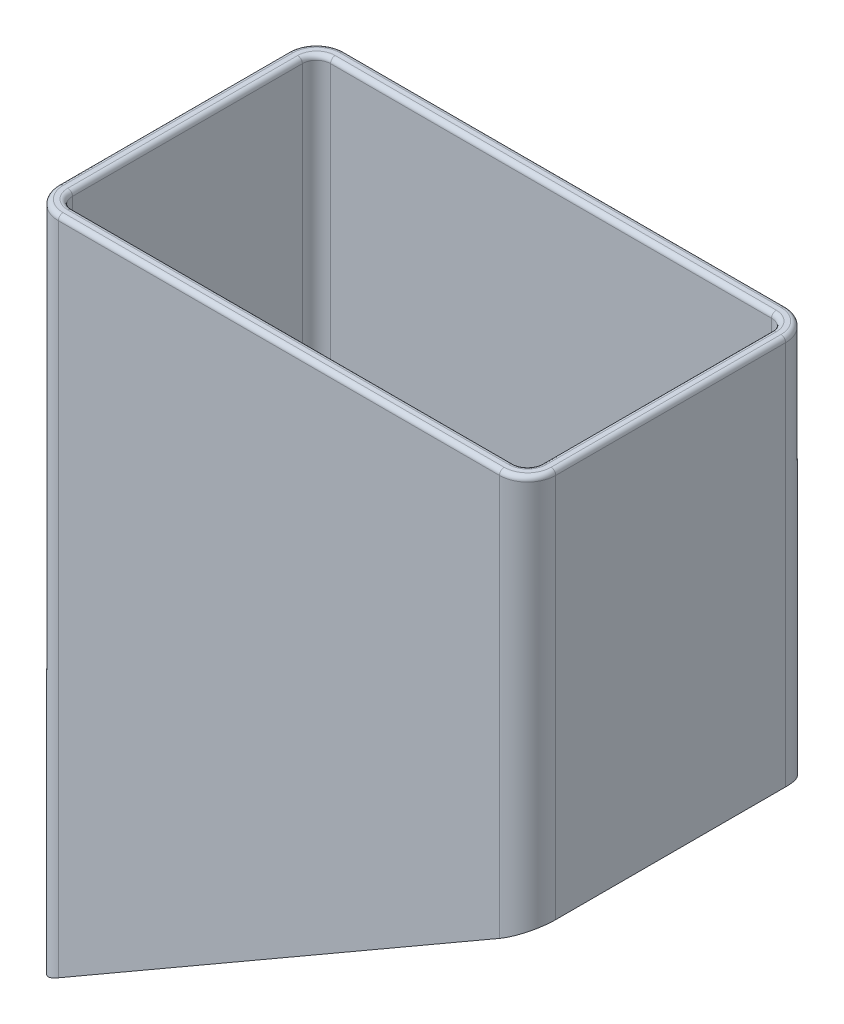
from build123d import *

# Parameters (mm, degrees)
BOSS_EXTRUDE1_DEPTH                                = 27.5
SKETCH3_W                                          = 106
SKETCH3_H                                          = 83
CUT_EXTRUDE1_DEPTH                                 = 28.5
SKETCH4_W                                          = 106
SKETCH4_H                                          = 83
BOSS_EXTRUDE2_DEPTH                                = 3
BOSS_EXTRUDE3_DEPTH                                = 30.5
FILLET1_R                                          = 3
FILLET2_R                                          = 6
FILLET3_R                                          = 1
CUT_EXTRUDE3_START                                 = -10
SKETCH8_R                                          = 6
CUT_EXTRUDE3_DEPTH                                 = 115.880108514
CSK_FOR_10_FLAT_HEAD_MACHINE_SCREW_100_D           = 5.6134
CSK_FOR_10_FLAT_HEAD_MACHINE_SCREW_100_CSINK_D     = 9.779
CSK_FOR_10_FLAT_HEAD_MACHINE_SCREW_100_CSINK_ANGLE = 100


with BuildPart() as part:
    # Sketch1 → Boss-Extrude1 (new body, symmetric)
    with BuildSketch(Plane.XY):
        Polygon((-53, 80), (-50, 80), (-50, 0), (50, 0), (50, 80), (53, 80), (53, -3), (-53, -3), align=None)
    extrude(amount=BOSS_EXTRUDE1_DEPTH, both=True)

    # Sketch3 → Cut-Extrude1 (cut, through all)
    with BuildSketch(Plane.XY):
        with Locations((0, 38.5)):
            Rectangle(SKETCH3_W, SKETCH3_H)
    extrude(amount=-CUT_EXTRUDE1_DEPTH, mode=Mode.SUBTRACT)

    # Sketch4 → Boss-Extrude2 (add)
    with BuildSketch(Plane.XY.offset(27.5)):
        with Locations((0, 38.5)):
            Rectangle(SKETCH4_W, SKETCH4_H)
    extrude(amount=BOSS_EXTRUDE2_DEPTH)

    # Sketch5 → Boss-Extrude3 (add)
    with BuildSketch(Plane.XY.offset(30.5)):
        Polygon((-53, -3), (-53, -64.199128534), (53, -3), align=None)
    extrude(amount=-BOSS_EXTRUDE3_DEPTH)

    # Fillet1
    fillet1_edges = [part.edges().sort_by_distance(p)[0] for p in [
        (-50, 0, 13.75),
        (50, 0, 13.75),
        (50, 40, 27.5),
        (0, 0, 27.5),
        (-50, 40, 27.5),
    ]]
    fillet(fillet1_edges, radius=FILLET1_R)

    # Fillet2
    fillet2_edges = [part.edges().sort_by_distance(p)[0] for p in [
        (-53, 7.900435733, 30.5),
        (53, 38.5, 30.5),
    ]]
    fillet(fillet2_edges, radius=FILLET2_R)

    # Fillet3
    fillet3_edges = [part.edges().sort_by_distance(p)[0] for p in [
        (0, 80, 30.5),
        (-53, 80, 12.25),
        (53, 80, 12.25),
        (51.242640687, 80, 28.742640687),
        (-51.242640687, 80, 28.742640687),
        (0, 80, 27.5),
        (50, 80, 12.25),
        (-50, 80, 12.25),
        (49.121320344, 80, 26.621320344),
        (-49.121320344, 80, 26.621320344),
    ]]
    fillet(fillet3_edges, radius=FILLET3_R)

    # Sketch8 → Cut-Extrude3 (cut, through all)
    with BuildSketch(Plane(origin=(14.549038106, -25.1996732, 0), x_dir=(0.866025404, 0.5, 0), z_dir=(0.5, -0.866025404, 0)).offset(CUT_EXTRUDE3_START)):
        with Locations((-57.998910668, 0)):
            Circle(SKETCH8_R)
        with Locations((24.399346401, 0)):
            Circle(SKETCH8_R)
    extrude(amount=-CUT_EXTRUDE3_DEPTH, mode=Mode.SUBTRACT)

    # CSK for #10 Flat Head Machine Screw (100)2 (through all)
    with Locations(Plane(origin=(-40.679491924, -45.538874496, 0), x_dir=(0.866025404, 0.5, 0), z_dir=(-0.5, 0.866025404, 0))):
        with Locations((0, 0), (82.398257068, 0)):
            CounterSinkHole(CSK_FOR_10_FLAT_HEAD_MACHINE_SCREW_100_D / 2, CSK_FOR_10_FLAT_HEAD_MACHINE_SCREW_100_CSINK_D / 2, counter_sink_angle=CSK_FOR_10_FLAT_HEAD_MACHINE_SCREW_100_CSINK_ANGLE)

    # Mirror1: part across plane


with BuildPart() as part_1:
    add(part.part)
    add(part.part.mirror(Plane.XY))


solid = part_1.part
